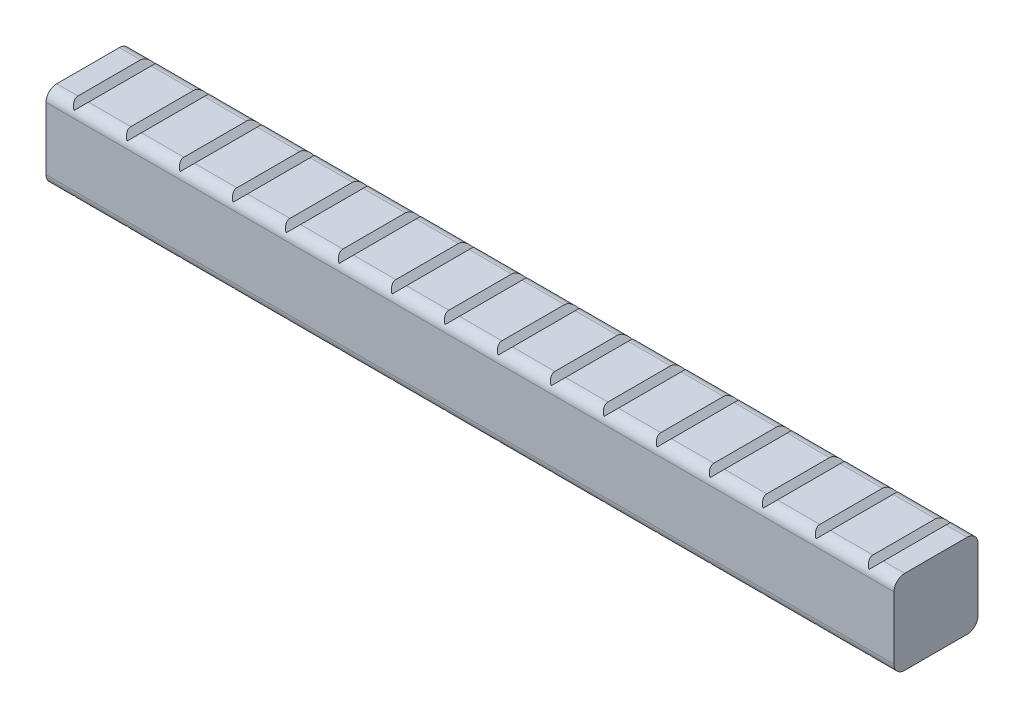
from build123d import *

# Parameters (mm, degrees)
BOSS_EXTRUDE1_DEPTH   = 203.2
CUT_EXTRUDE1_DEPTH    = 21.1422
LPATTERN1_COUNT       = 16
LPATTERN1_PITCH       = 12.7
MIRROR1_COPY_1_DEPTH  = 21.1422
MIRROR1_COPY_2_DEPTH  = 21.1422
MIRROR1_COPY_3_DEPTH  = 21.1422
MIRROR1_COPY_4_DEPTH  = 21.1422
MIRROR1_COPY_5_DEPTH  = 21.1422
MIRROR1_COPY_6_DEPTH  = 21.1422
MIRROR1_COPY_7_DEPTH  = 21.1422
MIRROR1_COPY_8_DEPTH  = 21.1422
MIRROR1_COPY_9_DEPTH  = 21.1422
MIRROR1_COPY_10_DEPTH = 21.1422
MIRROR1_COPY_11_DEPTH = 21.1422
MIRROR1_COPY_12_DEPTH = 21.1422
MIRROR1_COPY_13_DEPTH = 21.1422
MIRROR1_COPY_14_DEPTH = 21.1422
MIRROR1_COPY_15_DEPTH = 21.1422
SKETCH3_OUTSIDE_W     = 63.18
SKETCH3_OUTSIDE_H     = 63.18
CUT_EXTRUDE2_DEPTH    = 204.2


with BuildPart() as part:
    # Sketch1 → Boss-Extrude1 (new body)
    with BuildSketch(Plane(origin=(0, 0, 0), x_dir=(0, 0, -1), z_dir=(1, 0, 0))):
        Polygon((-7.5311, 10.0711), (-8.583202448, 10.0711), (-10.0711, 8.583202448), (-10.0711, 7.5311), (-10.0711, -7.5311), (-10.0711, -8.583202448), (-8.583202448, -10.0711), (-7.5311, -10.0711), (7.5311, -10.0711), (8.583202448, -10.0711), (10.0711, -8.583202448), (10.0711, -7.5311), (10.0711, 7.5311), (10.0711, 8.583202448), (8.583202448, 10.0711), (7.5311, 10.0711), align=None)
    extrude(amount=BOSS_EXTRUDE1_DEPTH)

    # Sketch2 → Cut-Extrude1 (cut, through all)
    with BuildSketch(Plane.XY.offset(10.0711)):
        Polygon((5.08, 10.0711), (6.35, 8.8011), (7.62, 10.0711), align=None)
    cut_extrude1 = extrude(amount=-CUT_EXTRUDE1_DEPTH, mode=Mode.SUBTRACT)

    # LPattern1: Cut-Extrude1 ×16
    with Locations(*[(i * LPATTERN1_PITCH, 0, 0) for i in range(1, LPATTERN1_COUNT)]):
        add(cut_extrude1, mode=Mode.SUBTRACT)

    # Mirror1: Cut-Extrude1 across plane
    add(cut_extrude1.mirror(Plane.ZX), mode=Mode.SUBTRACT)

    # Mirror1 copy 1 sketch → Mirror1 copy 1 (cut, through all)
    with BuildSketch(Plane(origin=(12.7, 0, 10.0711), x_dir=(1, 0, 0), z_dir=(0, 0, 1))):
        Polygon((5.08, -10.0711), (6.35, -8.8011), (7.62, -10.0711), align=None)
    extrude(amount=-MIRROR1_COPY_1_DEPTH, mode=Mode.SUBTRACT)

    # Mirror1 copy 2 sketch → Mirror1 copy 2 (cut, through all)
    with BuildSketch(Plane(origin=(25.4, 0, 10.0711), x_dir=(1, 0, 0), z_dir=(0, 0, 1))):
        Polygon((5.08, -10.0711), (6.35, -8.8011), (7.62, -10.0711), align=None)
    extrude(amount=-MIRROR1_COPY_2_DEPTH, mode=Mode.SUBTRACT)

    # Mirror1 copy 3 sketch → Mirror1 copy 3 (cut, through all)
    with BuildSketch(Plane(origin=(38.1, 0, 10.0711), x_dir=(1, 0, 0), z_dir=(0, 0, 1))):
        Polygon((5.08, -10.0711), (6.35, -8.8011), (7.62, -10.0711), align=None)
    extrude(amount=-MIRROR1_COPY_3_DEPTH, mode=Mode.SUBTRACT)

    # Mirror1 copy 4 sketch → Mirror1 copy 4 (cut, through all)
    with BuildSketch(Plane(origin=(50.8, 0, 10.0711), x_dir=(1, 0, 0), z_dir=(0, 0, 1))):
        Polygon((5.08, -10.0711), (6.35, -8.8011), (7.62, -10.0711), align=None)
    extrude(amount=-MIRROR1_COPY_4_DEPTH, mode=Mode.SUBTRACT)

    # Mirror1 copy 5 sketch → Mirror1 copy 5 (cut, through all)
    with BuildSketch(Plane(origin=(63.5, 0, 10.0711), x_dir=(1, 0, 0), z_dir=(0, 0, 1))):
        Polygon((5.08, -10.0711), (6.35, -8.8011), (7.62, -10.0711), align=None)
    extrude(amount=-MIRROR1_COPY_5_DEPTH, mode=Mode.SUBTRACT)

    # Mirror1 copy 6 sketch → Mirror1 copy 6 (cut, through all)
    with BuildSketch(Plane(origin=(76.2, 0, 10.0711), x_dir=(1, 0, 0), z_dir=(0, 0, 1))):
        Polygon((5.08, -10.0711), (6.35, -8.8011), (7.62, -10.0711), align=None)
    extrude(amount=-MIRROR1_COPY_6_DEPTH, mode=Mode.SUBTRACT)

    # Mirror1 copy 7 sketch → Mirror1 copy 7 (cut, through all)
    with BuildSketch(Plane(origin=(88.9, 0, 10.0711), x_dir=(1, 0, 0), z_dir=(0, 0, 1))):
        Polygon((5.08, -10.0711), (6.35, -8.8011), (7.62, -10.0711), align=None)
    extrude(amount=-MIRROR1_COPY_7_DEPTH, mode=Mode.SUBTRACT)

    # Mirror1 copy 8 sketch → Mirror1 copy 8 (cut, through all)
    with BuildSketch(Plane(origin=(101.6, 0, 10.0711), x_dir=(1, 0, 0), z_dir=(0, 0, 1))):
        Polygon((5.08, -10.0711), (6.35, -8.8011), (7.62, -10.0711), align=None)
    extrude(amount=-MIRROR1_COPY_8_DEPTH, mode=Mode.SUBTRACT)

    # Mirror1 copy 9 sketch → Mirror1 copy 9 (cut, through all)
    with BuildSketch(Plane(origin=(114.3, 0, 10.0711), x_dir=(1, 0, 0), z_dir=(0, 0, 1))):
        Polygon((5.08, -10.0711), (6.35, -8.8011), (7.62, -10.0711), align=None)
    extrude(amount=-MIRROR1_COPY_9_DEPTH, mode=Mode.SUBTRACT)

    # Mirror1 copy 10 sketch → Mirror1 copy 10 (cut, through all)
    with BuildSketch(Plane(origin=(127, 0, 10.0711), x_dir=(1, 0, 0), z_dir=(0, 0, 1))):
        Polygon((5.08, -10.0711), (6.35, -8.8011), (7.62, -10.0711), align=None)
    extrude(amount=-MIRROR1_COPY_10_DEPTH, mode=Mode.SUBTRACT)

    # Mirror1 copy 11 sketch → Mirror1 copy 11 (cut, through all)
    with BuildSketch(Plane(origin=(139.7, 0, 10.0711), x_dir=(1, 0, 0), z_dir=(0, 0, 1))):
        Polygon((5.08, -10.0711), (6.35, -8.8011), (7.62, -10.0711), align=None)
    extrude(amount=-MIRROR1_COPY_11_DEPTH, mode=Mode.SUBTRACT)

    # Mirror1 copy 12 sketch → Mirror1 copy 12 (cut, through all)
    with BuildSketch(Plane(origin=(152.4, 0, 10.0711), x_dir=(1, 0, 0), z_dir=(0, 0, 1))):
        Polygon((5.08, -10.0711), (6.35, -8.8011), (7.62, -10.0711), align=None)
    extrude(amount=-MIRROR1_COPY_12_DEPTH, mode=Mode.SUBTRACT)

    # Mirror1 copy 13 sketch → Mirror1 copy 13 (cut, through all)
    with BuildSketch(Plane(origin=(165.1, 0, 10.0711), x_dir=(1, 0, 0), z_dir=(0, 0, 1))):
        Polygon((5.08, -10.0711), (6.35, -8.8011), (7.62, -10.0711), align=None)
    extrude(amount=-MIRROR1_COPY_13_DEPTH, mode=Mode.SUBTRACT)

    # Mirror1 copy 14 sketch → Mirror1 copy 14 (cut, through all)
    with BuildSketch(Plane(origin=(177.8, 0, 10.0711), x_dir=(1, 0, 0), z_dir=(0, 0, 1))):
        Polygon((5.08, -10.0711), (6.35, -8.8011), (7.62, -10.0711), align=None)
    extrude(amount=-MIRROR1_COPY_14_DEPTH, mode=Mode.SUBTRACT)

    # Mirror1 copy 15 sketch → Mirror1 copy 15 (cut, through all)
    with BuildSketch(Plane(origin=(190.5, 0, 10.0711), x_dir=(1, 0, 0), z_dir=(0, 0, 1))):
        Polygon((5.08, -10.0711), (6.35, -8.8011), (7.62, -10.0711), align=None)
    extrude(amount=-MIRROR1_COPY_15_DEPTH, mode=Mode.SUBTRACT)

    # Sketch3 outside → Cut-Extrude2 (cut, through all)
    with BuildSketch(Plane.ZY):
        Rectangle(SKETCH3_OUTSIDE_W, SKETCH3_OUTSIDE_H)
        with BuildLine():
            Line((10.0711, -7.5057), (10.0711, 7.5057))
            ThreePointArc((10.0711, 7.5057), (9.319711736, 9.319711736), (7.5057, 10.0711))
            Line((7.5057, 10.0711), (-7.5057, 10.0711))
            ThreePointArc((-7.5057, 10.0711), (-9.319711736, 9.319711736), (-10.0711, 7.5057))
            Line((-10.0711, 7.5057), (-10.0711, -7.5057))
            ThreePointArc((-10.0711, -7.5057), (-9.319711736, -9.319711736), (-7.5057, -10.0711))
            Line((-7.5057, -10.0711), (7.5057, -10.0711))
            ThreePointArc((7.5057, -10.0711), (9.319711736, -9.319711736), (10.0711, -7.5057))
        make_face(mode=Mode.SUBTRACT)
    extrude(amount=-CUT_EXTRUDE2_DEPTH, mode=Mode.SUBTRACT)


solid = part.part
